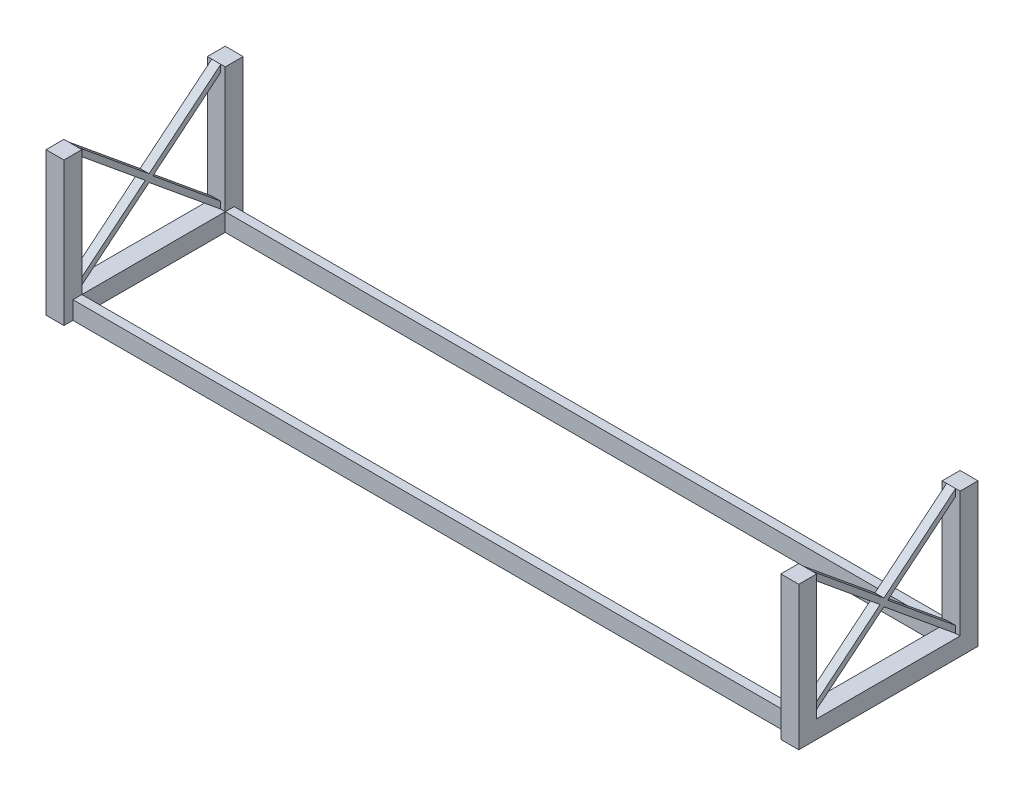
from build123d import *

# Parameters (mm, degrees)
BOSS_EXTRUDE1_DEPTH = 5
BOSS_EXTRUDE2_DEPTH = 2.5
SKETCH2_W           = 200
SKETCH2_H           = 5
BOSS_EXTRUDE3_DEPTH = 10


with BuildPart() as part:
    # Sketch1 → Boss-Extrude1 (new, symmetric)
    with BuildSketch(Plane(origin=(0, 0, 0), x_dir=(0, 0, -1), z_dir=(1, 0, 0))):
        Polygon((-50, 80), (-50, 0), (50, 0), (50, 80), (40, 80), (40, 76.135024964), (40, 13.864975036), (40, 10), (-40, 10), (-40, 13.864975036), (-40, 76.135024964), (-40, 80), align=None)
    extrude(amount=BOSS_EXTRUDE1_DEPTH, both=True)

    # Sketch1_4 → Boss-Extrude2 (add, symmetric)
    with BuildSketch(Plane(origin=(0, 0, 0), x_dir=(0, 0, -1), z_dir=(1, 0, 0))):
        Polygon((0, 47.12132), (-40, 80), (-40, 76.135024964), (-2.12132, 45), (-40, 13.864975036), (-40, 10), (0, 42.87868), (40, 10), (40, 13.864975036), (2.12132, 45), (40, 76.135024964), (40, 80), align=None)
    extrude(amount=BOSS_EXTRUDE2_DEPTH, both=True)

    # Sketch2 → Boss-Extrude3 (add)
    with BuildSketch(Plane(origin=(0, 0, 0), x_dir=(1, 0, 0), z_dir=(0, 1, 0))):
        with Locations((105, 42.5)):
            Rectangle(SKETCH2_W, SKETCH2_H)
        with Locations((105, -42.5)):
            Rectangle(SKETCH2_W, SKETCH2_H)
    extrude(amount=BOSS_EXTRUDE3_DEPTH)

    # Mirror1: part across plane


with BuildPart() as part_1:
    add(part.part)
    add(part.part.mirror(Plane(origin=(205, 10, 40), x_dir=(0, 0, 1), z_dir=(-1, 0, 0))))


solid = part_1.part
